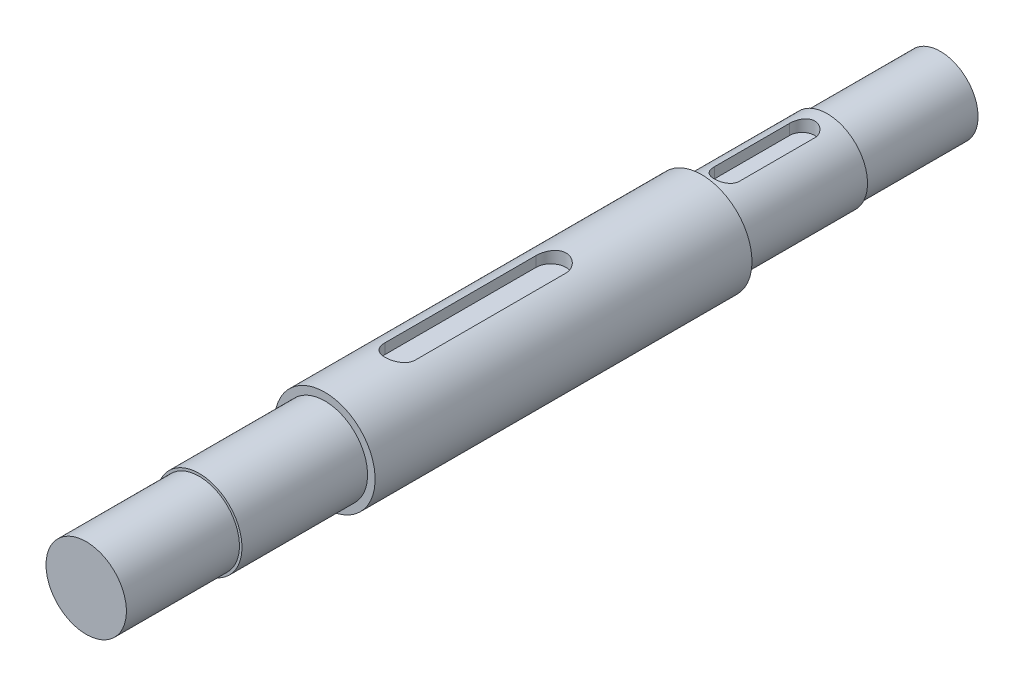
from build123d import *

# Parameters (mm, degrees)
CUT_EXTRUDE1_DEPTH  = 5
CUT_EXTRUDE11_DEPTH = 5


with BuildPart() as part:
    # Sketch1 → Revolve1 (revolve)
    with BuildSketch(Plane(origin=(0, 0, 0), x_dir=(1, 0, 0), z_dir=(0, 1, 0))):
        Polygon((0, 0), (0, -265), (0, -340), (16, -340), (16, -295), (17, -295), (17, -245), (20, -245), (20, -95), (16, -95), (16, -45), (15, -45), (15, 0), align=None)
    revolve(axis=Axis((0, 0, 0), (0, 0, 1)))

    # Sketch3 → Cut-Extrude1 (cut)
    with BuildSketch(Plane(origin=(2.233419524, 16, 45), x_dir=(0, 0, -1), z_dir=(0, -1, 0))):
        with BuildLine():
            Line((-10, 2.766580476), (-40, 2.766580476))
            ThreePointArc((-40, 2.766580476), (-45, -2.233419524), (-40, -7.233419524))
            Line((-40, -7.233419524), (-10, -7.233419524))
            ThreePointArc((-10, -7.233419524), (-5, -2.233419524), (-10, 2.766580476))
        make_face()
    extrude(amount=CUT_EXTRUDE1_DEPTH, mode=Mode.SUBTRACT)

    # Sketch31 → Cut-Extrude11 (cut)
    with BuildSketch(Plane(origin=(1.137793825, 20, 245), x_dir=(0, 0, 1), z_dir=(0, -1, 0))):
        with BuildLine():
            Line((-30, 7.137793825), (-90, 7.137793825))
            ThreePointArc((-90, 7.137793825), (-96, 1.137793825), (-90, -4.862206175))
            Line((-90, -4.862206175), (-30, -4.862206175))
            ThreePointArc((-30, -4.862206175), (-24, 1.137793825), (-30, 7.137793825))
        make_face()
    extrude(amount=CUT_EXTRUDE11_DEPTH, mode=Mode.SUBTRACT)


solid = part.part
